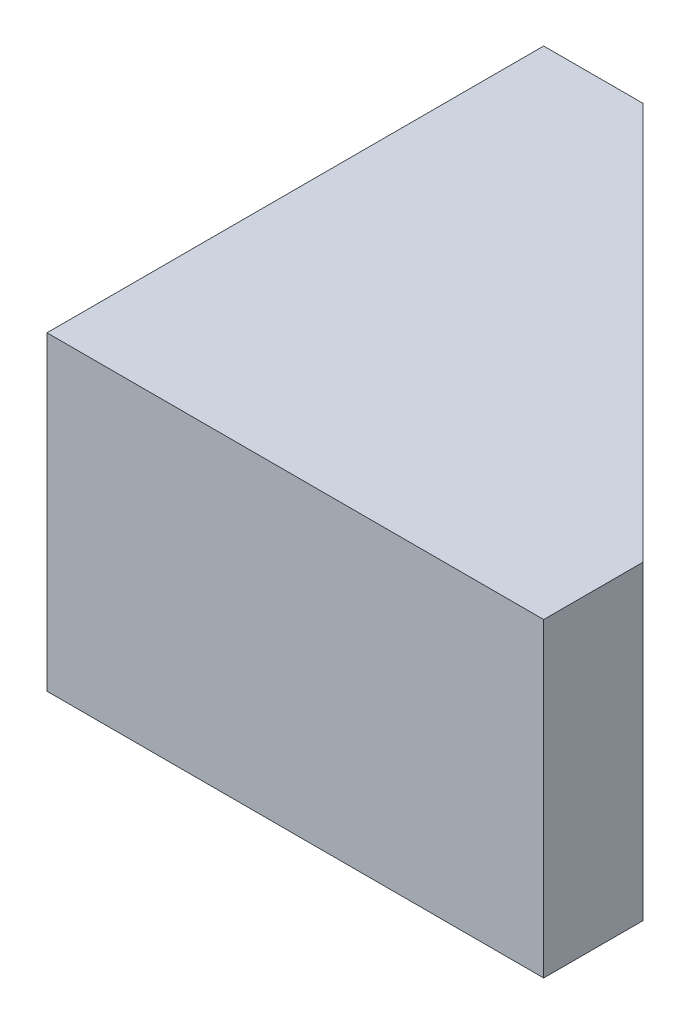
from build123d import *

# Parameters (mm, degrees)
SALIENTE_EXTRUIR1_DEPTH = 25


with BuildPart() as part:
    # Croquis1 → Saliente-Extruir1 (new body)
    with BuildSketch(Plane(origin=(0, 0, 0), x_dir=(1, 0, 0), z_dir=(0, 1, 0))):
        Polygon((0, 0), (-40, 0), (-40, 40), (-32, 40), (0, 8), align=None)
    extrude(amount=SALIENTE_EXTRUIR1_DEPTH)


solid = part.part
